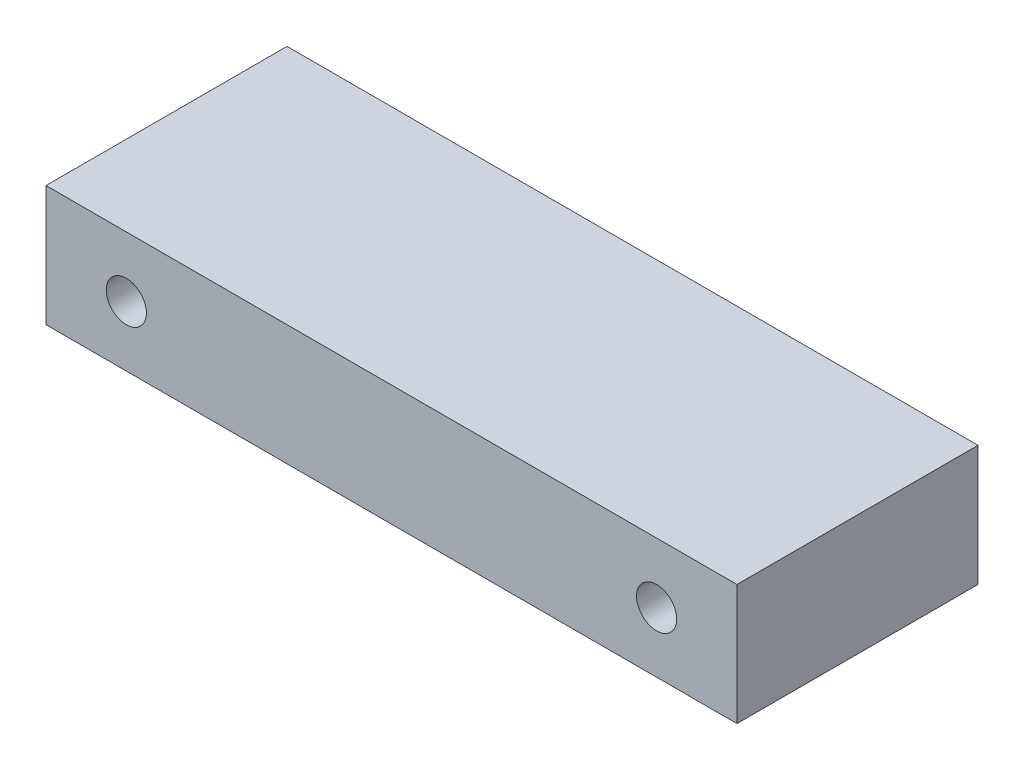
from build123d import *

# Parameters (mm, degrees)
SKETCH1_W        = 109.22
SKETCH1_H        = 19.05
SKETCH1_R        = 3.175
EXTRUSION1_DEPTH = 38.1


with BuildPart() as part:
    # Sketch1 → Extrusion1 (new body)
    with BuildSketch(Plane.XY):
        with Locations((54.61, 9.525)):
            Rectangle(SKETCH1_W, SKETCH1_H)
        with Locations((96.52, 9.525)):
            Circle(SKETCH1_R, mode=Mode.SUBTRACT)
        with Locations((12.7, 9.525)):
            Circle(SKETCH1_R, mode=Mode.SUBTRACT)
    extrude(amount=EXTRUSION1_DEPTH)


solid = part.part
